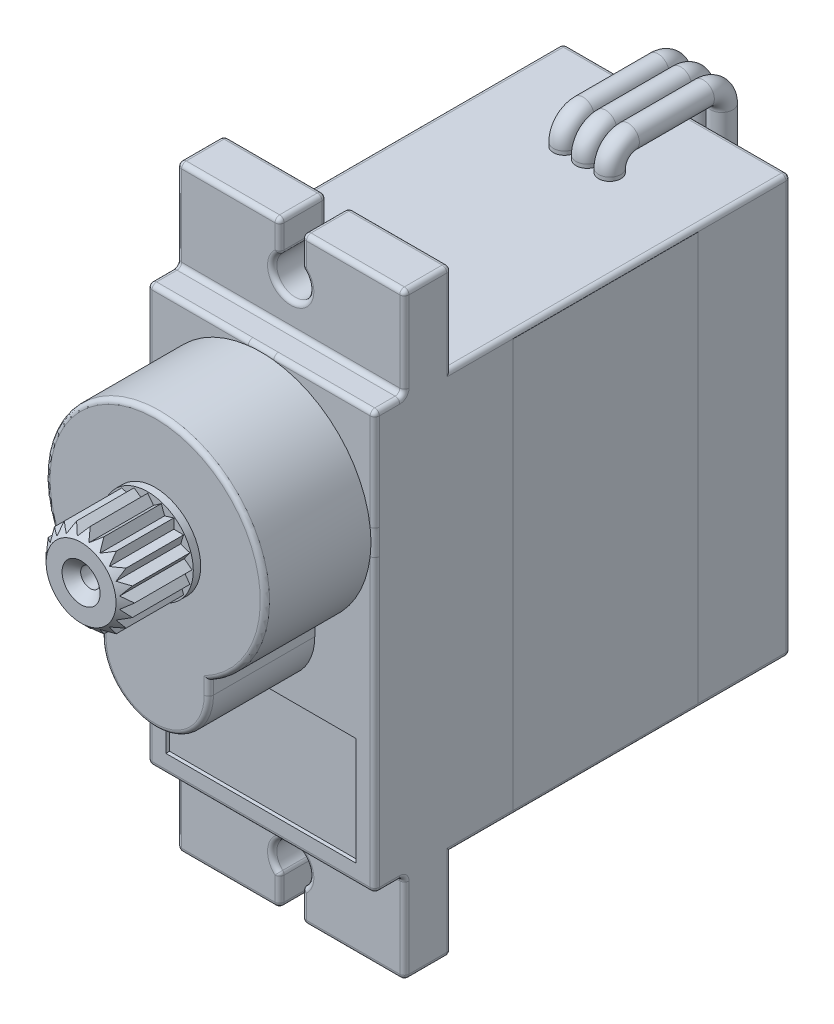
from build123d import *

# Parameters (mm, degrees)
SKETCH1_W               = 12.28
SKETCH1_H               = 22.55
MAIN_BODY_DEPTH         = 22.46
SKETCH1_3_R             = 5.93
FRONT_DIAL_DEPTH        = 5.72
SKETCH3_R               = 2.46
GEAR_BASE_DEPTH         = 0.4
GEAR_DEPTH              = 4
FLANGE_DEPTH            = 2.54
FLANGE_SHELL_DEPTH      = 1
BODY_FILLET_R           = 0.25
SKETCH6_W               = 10.28
SKETCH6_H               = 5.83
FRONT_FACE_DIVOT_DEPTH  = 0.2
SKETCH7_R               = 0.875
SCREW_HOLES_DEPTH       = 1
SCREWS_DEPTH            = 1
SCREW_CROSS_DEPTH       = 0.7
SCREW_FILLET_R          = 0.1
SKETCH10_W              = 10
SKETCH10_H              = 22.05
STICKER_BASE_DEPTH      = 6.24
STICKER_BASE_DEPTH_BACK = 6.15
SKETCH12_R              = 0.6
WIRE_TRIM_DEPTH         = 7.15
WIRE_TRIM_DEPTH_BACK    = 7.24


with BuildPart() as part:
    # Sketch1 → Main Body (new body)
    with BuildSketch(Plane.XY):
        with Locations((0, -5.135)):
            Rectangle(SKETCH1_W, SKETCH1_H)
    extrude(amount=-MAIN_BODY_DEPTH)

    # Sketch1_3 → Front Dial (add)
    with BuildSketch(Plane.XY):
        with BuildLine():
            ThreePointArc((-2.9, -5.93), (0, -8.83), (2.9, -5.93))
            Line((2.9, -5.93), (2.9, -5.172513896))
            ThreePointArc((2.9, -5.172513896), (0, -5.93), (-2.9, -5.172513896))
            Line((-2.9, -5.172513896), (-2.9, -5.93))
        make_face()
        Circle(SKETCH1_3_R)
    extrude(amount=FRONT_DIAL_DEPTH)

    # Sketch3 → Gear Base (add)
    with BuildSketch(Plane.XY.offset(5.72)):
        Circle(SKETCH3_R)
    extrude(amount=GEAR_BASE_DEPTH)

    # Sketch3_3 → Gear (add)
    with BuildSketch(Plane.XY.offset(5.72)):
        Polygon((-0.31286893, 1.975376681), (0, 2.39), (0.31286893, 1.975376681), (0.738550617, 2.273025074), (0.907980999, 1.782013048), (1.404806753, 1.933550617), (1.414213562, 1.414213562), (1.933550617, 1.404806753), (1.782013048, 0.907980999), (2.273025074, 0.738550617), (1.975376681, 0.31286893), (2.39, 0), (1.975376681, -0.31286893), (2.273025074, -0.738550617), (1.782013048, -0.907980999), (1.933550617, -1.404806753), (1.414213562, -1.414213562), (1.404806753, -1.933550617), (0.907980999, -1.782013048), (0.738550617, -2.273025074), (0.31286893, -1.975376681), (0, -2.39), (-0.31286893, -1.975376681), (-0.738550617, -2.273025074), (-0.907980999, -1.782013048), (-1.404806753, -1.933550617), (-1.414213562, -1.414213562), (-1.933550617, -1.404806753), (-1.782013048, -0.907980999), (-2.273025074, -0.738550617), (-1.975376681, -0.31286893), (-2.39, 0), (-1.975376681, 0.31286893), (-2.273025074, 0.738550617), (-1.782013048, 0.907980999), (-1.933550617, 1.404806753), (-1.414213562, 1.414213562), (-1.404806753, 1.933550617), (-0.907980999, 1.782013048), (-0.738550617, 2.273025074), align=None)
    extrude(amount=GEAR_DEPTH)

    # Sketch4 → Gear Front (revolve, cut)
    with BuildSketch(Plane(origin=(0, 0, 0), x_dir=(1, 0, 0), z_dir=(0, 1, 0))):
        Polygon((0, -10.417481251), (0, -6.12), (0.5, -6.12), (0.522139063, -9.22001275), (1.025709773, -9.72), (1.89, -9.72), (2.39, -9.22), (2.39, -7.833163317), (3.933149175, -7.833163317), (3.933149175, -10.417481251), align=None)
    revolve(axis=Axis((0, 0, 0), (0, 0, 1)), mode=Mode.SUBTRACT)

    # Sketch2 → Flange (add)
    with BuildSketch(Plane.XY.offset(-1.6)):
        with BuildLine():
            Line((-6.14, 6.14), (6.14, 6.14))
            Line((6.14, 6.14), (6.14, 11))
            Line((6.14, 11), (0.6, 11))
            Line((0.6, 11), (0.6, 9.37))
            ThreePointArc((0.6, 9.37), (0, 7.57), (-0.6, 9.37))
            Line((-0.6, 9.37), (-0.6, 11))
            Line((-0.6, 11), (-6.14, 11))
            Line((-6.14, 11), (-6.14, 6.14))
        make_face()
        with BuildLine():
            Line((0.6, -21.27), (6.14, -21.27))
            Line((6.14, -21.27), (6.14, -16.41))
            Line((6.14, -16.41), (-6.14, -16.41))
            Line((-6.14, -16.41), (-6.14, -21.27))
            Line((-6.14, -21.27), (-0.6, -21.27))
            Line((-0.6, -21.27), (-0.6, -19.64))
            ThreePointArc((-0.6, -19.64), (0, -17.84), (0.6, -19.64))
            Line((0.6, -19.64), (0.6, -21.27))
        make_face()
    extrude(amount=-FLANGE_DEPTH)

    # Sketch5 → Flange Shell (cut)
    with BuildSketch(Plane(origin=(0, 0, -4.14), x_dir=(-1, 0, 0), z_dir=(0, 0, -1))):
        with BuildLine():
            Line((-5.34, 6.14), (5.34, 6.14))
            Line((5.34, 6.14), (5.34, 10.2))
            Line((5.34, 10.2), (1.4, 10.2))
            Line((1.4, 10.2), (1.4, 9.70137085))
            ThreePointArc((1.4, 9.70137085), (0, 6.77), (-1.4, 9.70137085))
            Line((-1.4, 9.70137085), (-1.4, 10.2))
            Line((-1.4, 10.2), (-5.34, 10.2))
            Line((-5.34, 10.2), (-5.34, 6.14))
        make_face()
        with BuildLine():
            Line((-5.34, -16.41), (-5.34, -20.47))
            Line((-5.34, -20.47), (-1.4, -20.47))
            Line((-1.4, -20.47), (-1.4, -19.97137085))
            ThreePointArc((-1.4, -19.97137085), (0, -17.04), (1.4, -19.97137085))
            Line((1.4, -19.97137085), (1.4, -20.47))
            Line((1.4, -20.47), (5.34, -20.47))
            Line((5.34, -20.47), (5.34, -16.41))
            Line((5.34, -16.41), (-5.34, -16.41))
        make_face()
    extrude(amount=-FLANGE_SHELL_DEPTH, mode=Mode.SUBTRACT)

    # Body Fillet
    body_fillet_edges = [part.edges().sort_by_distance(p)[0] for p in [
        (0, 6.14, -22.46),
        (-2.9, -5.551256948, 5.72),
        (-6.14, -5.135, -22.46),
        (0, -8.83, 5.72),
        (2.9, -5.551256948, 5.72),
        (0, 5.93, 5.72),
        (6.14, 6.14, -0.8),
        (-6.14, 6.14, -0.8),
        (-6.14, 8.57, -4.14),
        (-3.37, 11, -4.14),
        (-6.14, 11, -2.87),
        (-0.6, 10.185, -4.14),
        (-0.6, 11, -2.87),
        (0, 7.57, -4.14),
        (-0.6, 9.37, -2.87),
        (0.6, 10.185, -4.14),
        (0.6, 9.37, -2.87),
        (3.37, 11, -4.14),
        (0.6, 11, -2.87),
        (6.14, 8.57, -4.14),
        (6.14, 11, -2.87),
        (-6.14, 8.57, -1.6),
        (0, 6.14, -1.6),
        (6.14, 8.57, -1.6),
        (3.37, 11, -1.6),
        (0.6, 10.185, -1.6),
        (0, 7.57, -1.6),
        (-0.6, 10.185, -1.6),
        (-3.37, 11, -1.6),
        (-6.14, -16.41, -0.8),
        (6.14, -16.41, -0.8),
        (0, -17.84, -4.14),
        (0.6, -19.64, -2.87),
        (-0.6, -20.455, -4.14),
        (-0.6, -19.64, -2.87),
        (-3.37, -21.27, -4.14),
        (-0.6, -21.27, -2.87),
        (-6.14, -18.84, -4.14),
        (-6.14, -21.27, -2.87),
        (6.14, -18.84, -4.14),
        (3.37, -21.27, -4.14),
        (6.14, -21.27, -2.87),
        (0.6, -20.455, -4.14),
        (0.6, -21.27, -2.87),
        (0, -17.84, -1.6),
        (0.6, -20.455, -1.6),
        (3.37, -21.27, -1.6),
        (6.14, -18.84, -1.6),
        (0, -16.41, -1.6),
        (-6.14, -18.84, -1.6),
        (-3.37, -21.27, -1.6),
        (-0.6, -20.455, -1.6),
        (0, -16.41, -22.46),
        (-6.14, -5.135, 0),
        (0, 6.14, 0),
        (6.14, -5.135, 0),
        (0, -16.41, 0),
        (-6.14, -16.41, -13.3),
        (-6.14, 6.14, -13.3),
        (6.14, 6.14, -13.3),
        (6.14, -16.41, -13.3),
        (6.14, -5.135, -22.46),
    ]]
    fillet(body_fillet_edges, radius=BODY_FILLET_R)

    # Sketch6 → Front Face Divot (cut)
    with BuildSketch(Plane.XY):
        with Locations((0, -12.495)):
            Rectangle(SKETCH6_W, SKETCH6_H)
    extrude(amount=-FRONT_FACE_DIVOT_DEPTH, mode=Mode.SUBTRACT)

    # Sketch7 → Screw Holes (cut)
    with BuildSketch(Plane(origin=(0, 0, -22.46), x_dir=(-1, 0, 0), z_dir=(0, 0, -1))):
        with Locations((-4.765, 4.765)):
            Circle(SKETCH7_R)
        with Locations((4.765, 4.765)):
            Circle(SKETCH7_R)
        with Locations((4.765, -15.035)):
            Circle(SKETCH7_R)
        with Locations((-4.765, -15.035)):
            Circle(SKETCH7_R)
    extrude(amount=-SCREW_HOLES_DEPTH, mode=Mode.SUBTRACT)

    # Sketch8 → Screws (add)
    with BuildSketch(Plane(origin=(0, 0, -21.46), x_dir=(-1, 0, 0), z_dir=(0, 0, -1))):
        with BuildLine():
            ThreePointArc((4.004654684, -15.185), (4.216992245, -15.583007755), (4.615, -15.795345316))
            Line((4.615, -15.795345316), (4.615, -15.185))
            Line((4.615, -15.185), (4.004654684, -15.185))
        make_face()
        with BuildLine():
            Line((4.615, -14.885), (4.615, -14.274654684))
            ThreePointArc((4.615, -14.274654684), (4.216992245, -14.486992245), (4.004654684, -14.885))
            Line((4.004654684, -14.885), (4.615, -14.885))
        make_face()
        with BuildLine():
            Line((4.915, -14.885), (5.525345316, -14.885))
            ThreePointArc((5.525345316, -14.885), (5.313007755, -14.486992245), (4.915, -14.274654684))
            Line((4.915, -14.274654684), (4.915, -14.885))
        make_face()
        with BuildLine():
            ThreePointArc((4.915, -15.795345316), (5.313007755, -15.583007755), (5.525345316, -15.185))
            Line((5.525345316, -15.185), (4.915, -15.185))
            Line((4.915, -15.185), (4.915, -15.795345316))
        make_face()
        with BuildLine():
            ThreePointArc((-4.915, -14.274654684), (-5.313007755, -14.486992245), (-5.525345316, -14.885))
            Line((-5.525345316, -14.885), (-4.915, -14.885))
            Line((-4.915, -14.885), (-4.915, -14.274654684))
        make_face()
        with BuildLine():
            ThreePointArc((-4.004654684, -14.885), (-4.216992245, -14.486992245), (-4.615, -14.274654684))
            Line((-4.615, -14.274654684), (-4.615, -14.885))
            Line((-4.615, -14.885), (-4.004654684, -14.885))
        make_face()
        with BuildLine():
            Line((-4.615, -15.185), (-4.615, -15.795345316))
            ThreePointArc((-4.615, -15.795345316), (-4.216992245, -15.583007755), (-4.004654684, -15.185))
            Line((-4.004654684, -15.185), (-4.615, -15.185))
        make_face()
        with BuildLine():
            Line((-4.915, -15.185), (-5.525345316, -15.185))
            ThreePointArc((-5.525345316, -15.185), (-5.313007755, -15.583007755), (-4.915, -15.795345316))
            Line((-4.915, -15.795345316), (-4.915, -15.185))
        make_face()
        with BuildLine():
            ThreePointArc((-4.915, 5.525345316), (-5.313007755, 5.313007755), (-5.525345316, 4.915))
            Line((-5.525345316, 4.915), (-4.915, 4.915))
            Line((-4.915, 4.915), (-4.915, 5.525345316))
        make_face()
        with BuildLine():
            Line((-4.915, 4.615), (-5.525345316, 4.615))
            ThreePointArc((-5.525345316, 4.615), (-5.313007755, 4.216992245), (-4.915, 4.004654684))
            Line((-4.915, 4.004654684), (-4.915, 4.615))
        make_face()
        with BuildLine():
            ThreePointArc((-4.004654684, 4.915), (-4.216992245, 5.313007755), (-4.615, 5.525345316))
            Line((-4.615, 5.525345316), (-4.615, 4.915))
            Line((-4.615, 4.915), (-4.004654684, 4.915))
        make_face()
        with BuildLine():
            Line((-4.615, 4.615), (-4.615, 4.004654684))
            ThreePointArc((-4.615, 4.004654684), (-4.216992245, 4.216992245), (-4.004654684, 4.615))
            Line((-4.004654684, 4.615), (-4.615, 4.615))
        make_face()
        with BuildLine():
            ThreePointArc((5.525345316, 4.915), (5.313007755, 5.313007755), (4.915, 5.525345316))
            Line((4.915, 5.525345316), (4.915, 4.915))
            Line((4.915, 4.915), (5.525345316, 4.915))
        make_face()
        with BuildLine():
            ThreePointArc((4.915, 4.004654684), (5.313007755, 4.216992245), (5.525345316, 4.615))
            Line((5.525345316, 4.615), (4.915, 4.615))
            Line((4.915, 4.615), (4.915, 4.004654684))
        make_face()
        with BuildLine():
            Line((4.615, 4.615), (4.004654684, 4.615))
            ThreePointArc((4.004654684, 4.615), (4.216992245, 4.216992245), (4.615, 4.004654684))
            Line((4.615, 4.004654684), (4.615, 4.615))
        make_face()
        with BuildLine():
            Line((4.615, 4.915), (4.615, 5.525345316))
            ThreePointArc((4.615, 5.525345316), (4.216992245, 5.313007755), (4.004654684, 4.915))
            Line((4.004654684, 4.915), (4.615, 4.915))
        make_face()
    extrude(amount=SCREWS_DEPTH)

    # Sketch8_3 → Screw Cross (add)
    with BuildSketch(Plane(origin=(0, 0, -21.46), x_dir=(-1, 0, 0), z_dir=(0, 0, -1))):
        with BuildLine():
            ThreePointArc((4.915, 5.525345316), (4.765, 5.54), (4.615, 5.525345316))
            Line((4.615, 5.525345316), (4.615, 4.915))
            Line((4.615, 4.915), (4.004654684, 4.915))
            ThreePointArc((4.004654684, 4.915), (3.99, 4.765), (4.004654684, 4.615))
            Line((4.004654684, 4.615), (4.615, 4.615))
            Line((4.615, 4.615), (4.615, 4.004654684))
            ThreePointArc((4.615, 4.004654684), (4.765, 3.99), (4.915, 4.004654684))
            Line((4.915, 4.004654684), (4.915, 4.615))
            Line((4.915, 4.615), (5.525345316, 4.615))
            ThreePointArc((5.525345316, 4.615), (5.536327628, 4.689642917), (5.54, 4.765))
            ThreePointArc((5.54, 4.765), (5.536327628, 4.840357083), (5.525345316, 4.915))
            Line((5.525345316, 4.915), (4.915, 4.915))
            Line((4.915, 4.915), (4.915, 5.525345316))
        make_face()
        with BuildLine():
            ThreePointArc((-5.525345316, 4.915), (-5.54, 4.765), (-5.525345316, 4.615))
            Line((-5.525345316, 4.615), (-4.915, 4.615))
            Line((-4.915, 4.615), (-4.915, 4.004654684))
            ThreePointArc((-4.915, 4.004654684), (-4.765, 3.99), (-4.615, 4.004654684))
            Line((-4.615, 4.004654684), (-4.615, 4.615))
            Line((-4.615, 4.615), (-4.004654684, 4.615))
            ThreePointArc((-4.004654684, 4.615), (-3.993672372, 4.689642917), (-3.99, 4.765))
            ThreePointArc((-3.99, 4.765), (-3.993672372, 4.840357083), (-4.004654684, 4.915))
            Line((-4.004654684, 4.915), (-4.615, 4.915))
            Line((-4.615, 4.915), (-4.615, 5.525345316))
            ThreePointArc((-4.615, 5.525345316), (-4.765, 5.54), (-4.915, 5.525345316))
            Line((-4.915, 5.525345316), (-4.915, 4.915))
            Line((-4.915, 4.915), (-5.525345316, 4.915))
        make_face()
        with BuildLine():
            ThreePointArc((-5.525345316, -14.885), (-5.54, -15.035), (-5.525345316, -15.185))
            Line((-5.525345316, -15.185), (-4.915, -15.185))
            Line((-4.915, -15.185), (-4.915, -15.795345316))
            ThreePointArc((-4.915, -15.795345316), (-4.765, -15.81), (-4.615, -15.795345316))
            Line((-4.615, -15.795345316), (-4.615, -15.185))
            Line((-4.615, -15.185), (-4.004654684, -15.185))
            ThreePointArc((-4.004654684, -15.185), (-3.993672372, -15.110357083), (-3.99, -15.035))
            ThreePointArc((-3.99, -15.035), (-3.993672372, -14.959642917), (-4.004654684, -14.885))
            Line((-4.004654684, -14.885), (-4.615, -14.885))
            Line((-4.615, -14.885), (-4.615, -14.274654684))
            ThreePointArc((-4.615, -14.274654684), (-4.765, -14.26), (-4.915, -14.274654684))
            Line((-4.915, -14.274654684), (-4.915, -14.885))
            Line((-4.915, -14.885), (-5.525345316, -14.885))
        make_face()
        with BuildLine():
            ThreePointArc((5.54, -15.035), (5.536327628, -14.959642917), (5.525345316, -14.885))
            Line((5.525345316, -14.885), (4.915, -14.885))
            Line((4.915, -14.885), (4.915, -14.274654684))
            ThreePointArc((4.915, -14.274654684), (4.765, -14.26), (4.615, -14.274654684))
            Line((4.615, -14.274654684), (4.615, -14.885))
            Line((4.615, -14.885), (4.004654684, -14.885))
            ThreePointArc((4.004654684, -14.885), (3.99, -15.035), (4.004654684, -15.185))
            Line((4.004654684, -15.185), (4.615, -15.185))
            Line((4.615, -15.185), (4.615, -15.795345316))
            ThreePointArc((4.615, -15.795345316), (4.765, -15.81), (4.915, -15.795345316))
            Line((4.915, -15.795345316), (4.915, -15.185))
            Line((4.915, -15.185), (5.525345316, -15.185))
            ThreePointArc((5.525345316, -15.185), (5.536327628, -15.110357083), (5.54, -15.035))
        make_face()
    extrude(amount=SCREW_CROSS_DEPTH)

    # Screw Fillet
    screw_fillet_edges = [part.edges().sort_by_distance(p)[0] for p in [
        (-4.216992245, -15.583007755, -22.46),
        (-4.216992245, -14.486992245, -22.46),
        (-5.313007755, -14.486992245, -22.46),
        (-5.313007755, -15.583007755, -22.46),
        (5.313007755, -14.486992245, -22.46),
        (4.216992245, -14.486992245, -22.46),
        (4.216992245, -15.583007755, -22.46),
        (5.313007755, -15.583007755, -22.46),
        (5.313007755, 5.313007755, -22.46),
        (5.313007755, 4.216992245, -22.46),
        (4.216992245, 5.313007755, -22.46),
        (4.216992245, 4.216992245, -22.46),
        (-5.313007755, 5.313007755, -22.46),
        (-5.313007755, 4.216992245, -22.46),
        (-4.216992245, 4.216992245, -22.46),
        (-4.216992245, 5.313007755, -22.46),
    ]]
    fillet(screw_fillet_edges, radius=SCREW_FILLET_R)

    # Sketch10 → Sticker Base (add, two sides)
    with BuildSketch(Plane.ZY) as sticker_base_sk:
        with Locations((-12.46, -5.135)):
            Rectangle(SKETCH10_W, SKETCH10_H)
    extrude(amount=STICKER_BASE_DEPTH)
    extrude(sticker_base_sk.sketch, amount=-STICKER_BASE_DEPTH_BACK)

    # Wires 2: sweep along a path in Sketch13
    with BuildLine(Plane(origin=(0, 0, 0), x_dir=(0, 0, -1), z_dir=(1, 0, 0))) as wires_2_path:
        Line((17.61, 5.94), (17.61, 6.34))
        ThreePointArc((17.61, 6.34), (17.902893219, 7.047106781), (18.61, 7.34))
        Line((18.61, 7.34), (22.66, 7.34))
        ThreePointArc((22.66, 7.34), (23.367106781, 7.047106781), (23.66, 6.34))
        Line((23.66, 6.34), (23.66, 1.34))
    # Sketch12 → Wires 2 (sweep)
    with BuildSketch(Plane(origin=(0, 6.14, 0), x_dir=(1, 0, 0), z_dir=(0, 1, 0))):
        with Locations((0, 17.61)):
            Circle(SKETCH12_R)
        with Locations((1.22, 17.61)):
            Circle(SKETCH12_R)
        with Locations((-1.22, 17.61)):
            Circle(SKETCH12_R)
    sweep(path=wires_2_path.line)

    # Sketch14 → Wire Trim (cut, two sides)
    with BuildSketch(Plane(origin=(0, 0, 0), x_dir=(0, 0, -1), z_dir=(1, 0, 0))) as wire_trim_sk:
        Polygon((23.06, 1.34), (24.26, 1.34), (23.06, 2.54), align=None)
    extrude(amount=WIRE_TRIM_DEPTH, mode=Mode.SUBTRACT)
    extrude(wire_trim_sk.sketch, amount=-WIRE_TRIM_DEPTH_BACK, mode=Mode.SUBTRACT)


solid = part.part
